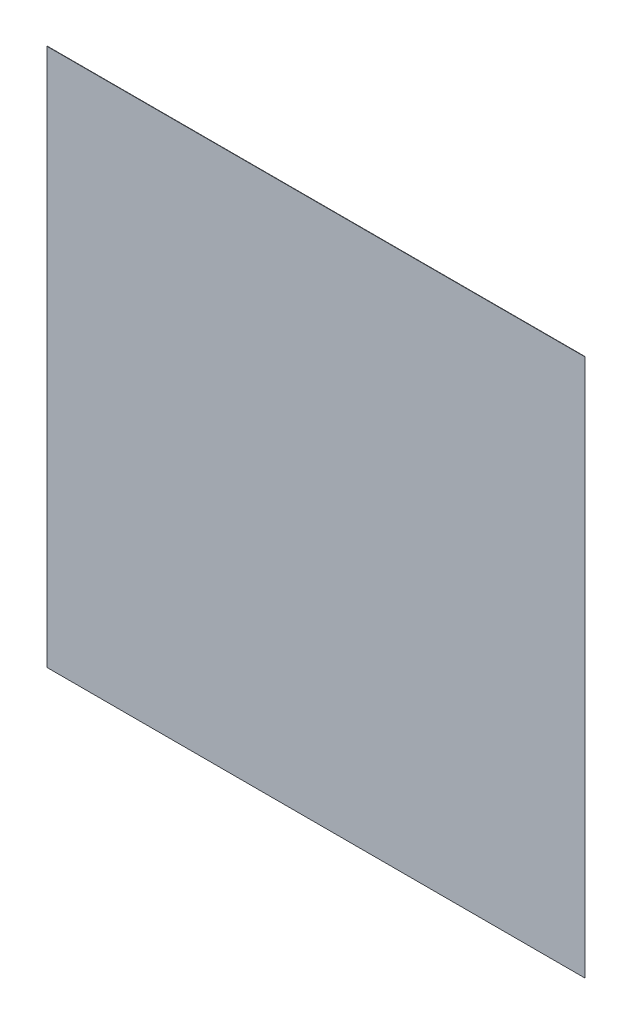
from build123d import *

# Parameters (mm, degrees)
SKETCH2_W           = 530
SKETCH2_H           = 530
BOSS_EXTRUDE1_DEPTH = 0.35


with BuildPart() as part:
    # Sketch2 → Boss-Extrude1 (new body)
    with BuildSketch(Plane.XY):
        Rectangle(SKETCH2_W, SKETCH2_H)
    extrude(amount=BOSS_EXTRUDE1_DEPTH)


solid = part.part
